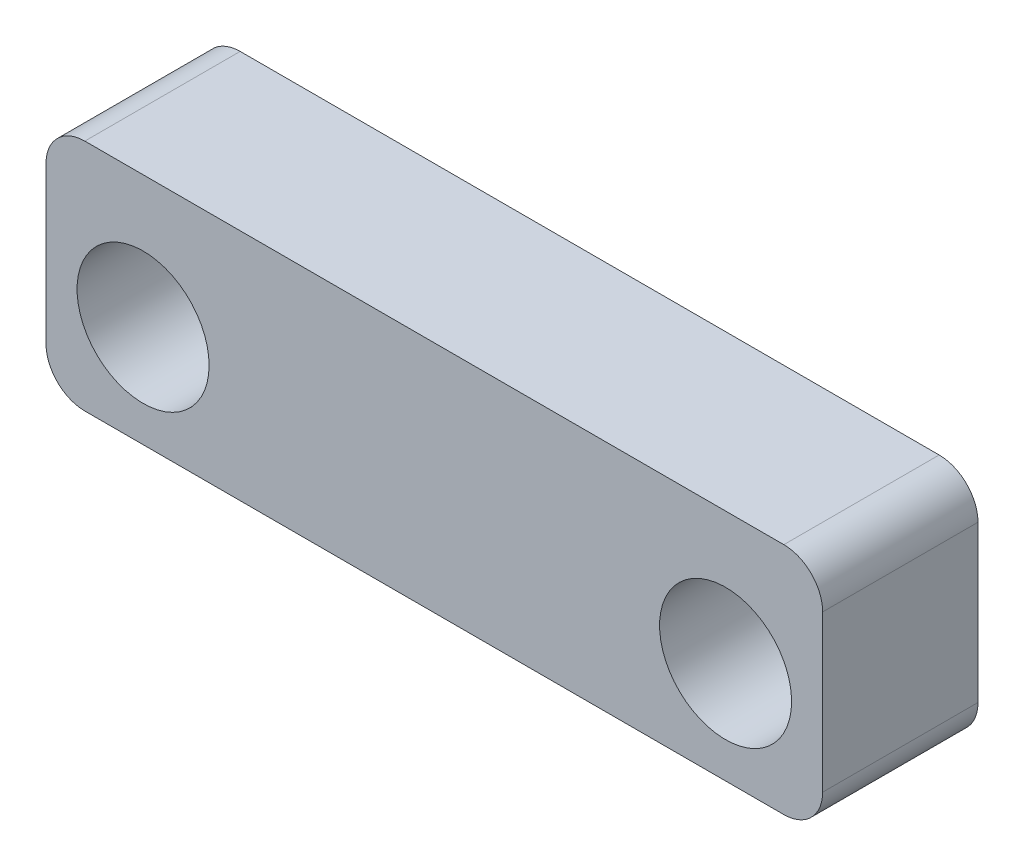
from build123d import *

# Parameters (mm, degrees)
SKETCH2_W                = 20
SKETCH2_H                = 6.020278893
BOSS_EXTRUDE1_DEPTH      = 4
FILLET1_R                = 1
M3_CLEARANCE_HOLE1_D     = 3.4
M3_CLEARANCE_HOLE1_DEPTH = 16.5
M3_CLEARANCE_HOLE1_TIP   = 1.021463052


with BuildPart() as part:
    # Sketch2 → Boss-Extrude1 (new body)
    with BuildSketch(Plane.XY.offset(133.365661293)):
        with Locations((-21.327645728, 38.168378797)):
            Rectangle(SKETCH2_W, SKETCH2_H)
    extrude(amount=BOSS_EXTRUDE1_DEPTH)

    # Fillet1
    fillet1_edges = [part.edges().sort_by_distance(p)[0] for p in [
        (-31.327645728, 41.178518244, 135.365661293),
        (-11.327645728, 41.178518244, 135.365661293),
        (-11.327645728, 35.158239351, 135.365661293),
        (-31.327645728, 35.158239351, 135.365661293),
    ]]
    fillet(fillet1_edges, radius=FILLET1_R)

    # M3 Clearance Hole1
    with Locations(Plane.XY.offset(137.365661293)):
        with Locations((-28.827645728, 37.778518244), (-13.827645728, 37.778518244)):
            Hole(M3_CLEARANCE_HOLE1_D / 2, depth=M3_CLEARANCE_HOLE1_DEPTH)
            with Locations((0, 0, -(M3_CLEARANCE_HOLE1_DEPTH + M3_CLEARANCE_HOLE1_TIP / 2))):  # 118° drill point
                Cone(0, M3_CLEARANCE_HOLE1_D / 2, M3_CLEARANCE_HOLE1_TIP, mode=Mode.SUBTRACT)


solid = part.part
